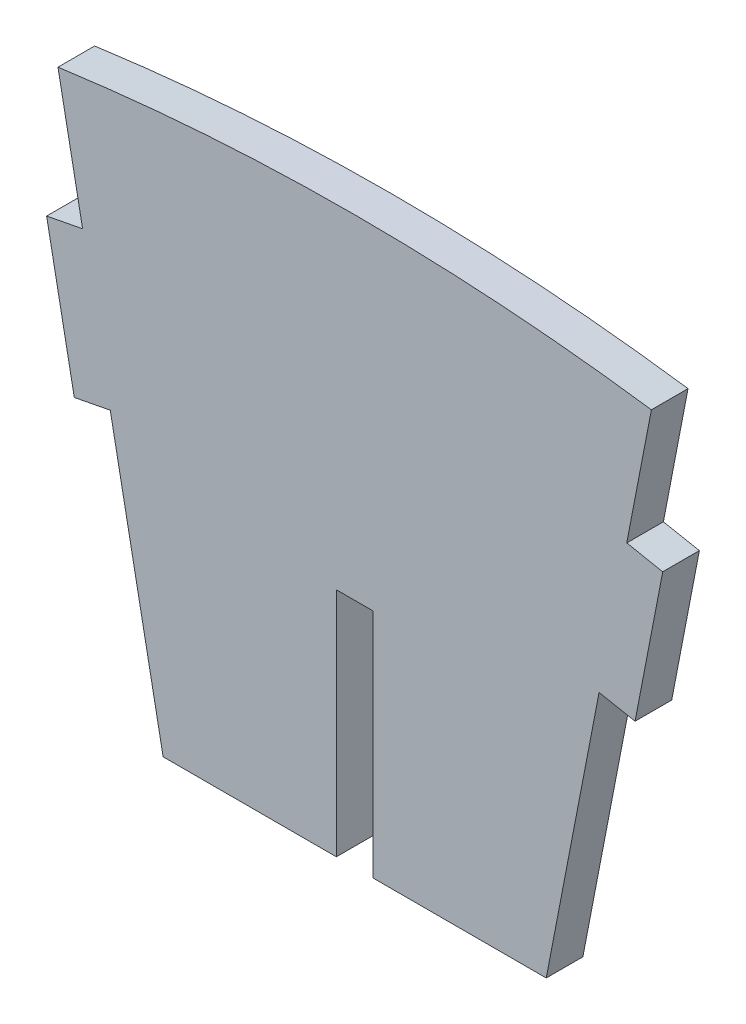
from build123d import *

# Parameters (mm, degrees)
BOSS_EXTRUDE1_DEPTH = 1.524


with BuildPart() as part:
    # Sketch1 → Boss-Extrude1 (new body)
    with BuildSketch(Plane.XY):
        with BuildLine():
            Line((0.085387869, 8.76561387), (0.085387869, -0.853085355))
            Line((0.085387869, -0.853085355), (-7.118587452, -0.853085355))
            Line((-7.118587452, -0.853085355), (-9.316419949, 10.53014054))
            Line((-9.316419949, 10.53014054), (-10.812784042, 10.241227919))
            Line((-10.812784042, 10.241227919), (-11.963375606, 16.20048264))
            Line((-11.963375606, 16.20048264), (-10.467011514, 16.489395261))
            Line((-10.467011514, 16.489395261), (-11.318780173, 20.900957592))
            Line((-11.318780173, 20.900957592), (-11.491926915, 21.797735888))
            ThreePointArc((-11.491926915, 21.797735888), (0.847387869, 22.653117291), (13.186702652, 21.797735888))
            Line((13.186702652, 21.797735888), (13.01355591, 20.900957592))
            Line((13.01355591, 20.900957592), (12.161787251, 16.489395261))
            Line((12.161787251, 16.489395261), (13.658151343, 16.20048264))
            Line((13.658151343, 16.20048264), (12.507559779, 10.241227919))
            Line((12.507559779, 10.241227919), (11.011195687, 10.53014054))
            Line((11.011195687, 10.53014054), (8.813363189, -0.853085355))
            Line((8.813363189, -0.853085355), (1.609387869, -0.853085355))
            Line((1.609387869, -0.853085355), (1.609387869, 8.76561387))
            Line((1.609387869, 8.76561387), (0.085387869, 8.76561387))
        make_face()
    extrude(amount=BOSS_EXTRUDE1_DEPTH)


solid = part.part
